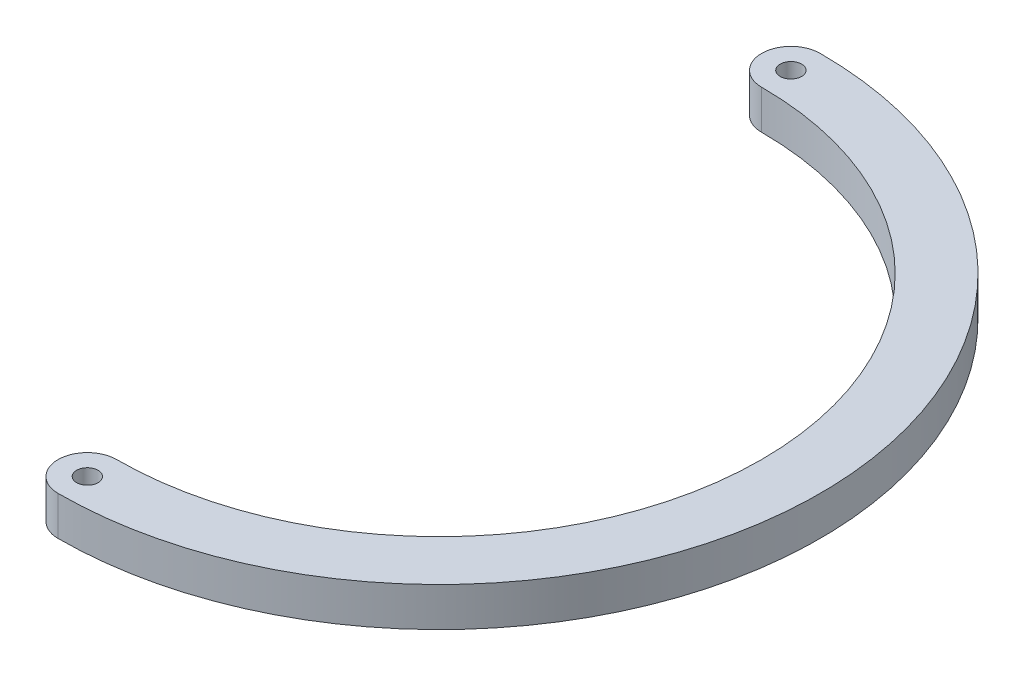
from build123d import *

# Parameters (mm, degrees)
BOSS_EXTRUDE1_DEPTH  = 5
M5_CLEARANCE_HOLE1_D = 5.5


with BuildPart() as part:
    # Sketch1 → Boss-Extrude1 (new body, symmetric)
    with BuildSketch(Plane(origin=(0, 0, 0), x_dir=(1, 0, 0), z_dir=(0, 1, 0))):
        with BuildLine():
            ThreePointArc((0, -82.55), (82.55, 0), (0, 82.55))
            ThreePointArc((0, 82.55), (-7.5, 90.05), (0, 97.55))
            ThreePointArc((0, 97.55), (97.55, 0), (0, -97.55))
            ThreePointArc((0, -97.55), (-7.5, -90.05), (0, -82.55))
        make_face()
    extrude(amount=BOSS_EXTRUDE1_DEPTH, both=True)

    # M5 Clearance Hole1 (through all)
    with Locations(Plane(origin=(0, 5, 0), x_dir=(1, 0, 0), z_dir=(0, 1, 0))):
        with Locations((0, 90.05), (0, -90.05)):
            Hole(M5_CLEARANCE_HOLE1_D / 2)


solid = part.part
